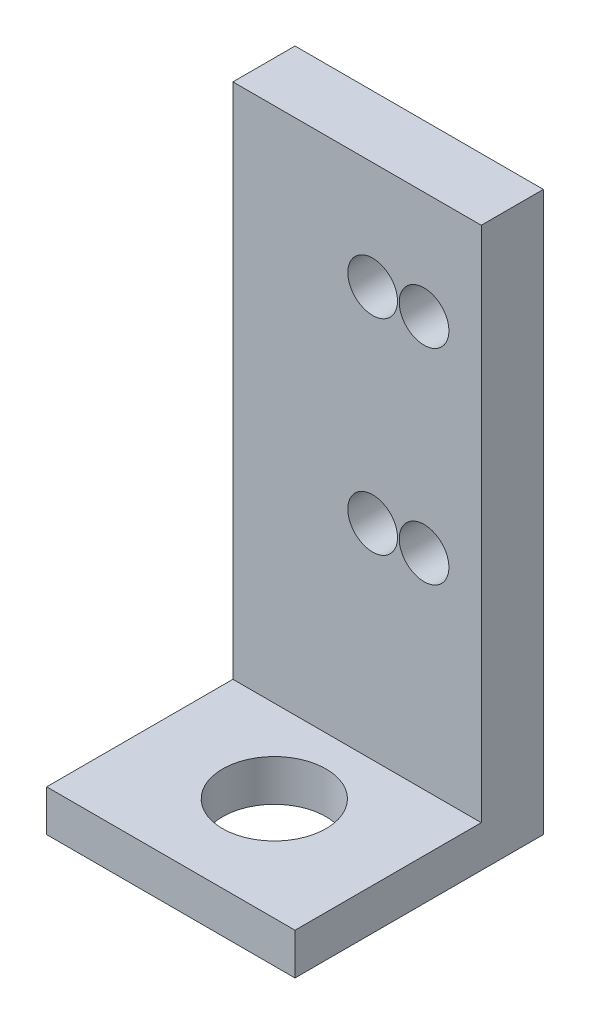
from build123d import *

# Parameters (mm, degrees)
SKETCH1_W           = 12
SKETCH1_H           = 27
BOSS_EXTRUDE1_DEPTH = 3
SKETCH2_W           = 12
SKETCH2_H           = 2
BOSS_EXTRUDE2_DEPTH = 9
SKETCH3_R           = 2.5
CUT_EXTRUDE1_DEPTH  = 10
SKETCH4_R           = 1.2
CUT_EXTRUDE2_DEPTH  = 10
SKETCH5_R           = 1.2
CUT_EXTRUDE3_DEPTH  = 10


with BuildPart() as part:
    # Sketch1 → Boss-Extrude1 (new body)
    with BuildSketch(Plane.XY):
        with Locations((6, 13.5)):
            Rectangle(SKETCH1_W, SKETCH1_H)
    extrude(amount=BOSS_EXTRUDE1_DEPTH)

    # Sketch2 → Boss-Extrude2 (add)
    with BuildSketch(Plane.XY.offset(3)):
        with Locations((6, 1)):
            Rectangle(SKETCH2_W, SKETCH2_H)
    extrude(amount=BOSS_EXTRUDE2_DEPTH)

    # Sketch3 → Cut-Extrude1 (cut)
    with BuildSketch(Plane(origin=(0, 2, 0), x_dir=(1, 0, 0), z_dir=(0, 1, 0))):
        with Locations((6, -7)):
            Circle(SKETCH3_R)
    extrude(amount=-CUT_EXTRUDE1_DEPTH, mode=Mode.SUBTRACT)

    # Sketch4 → Cut-Extrude2 (cut)
    with BuildSketch(Plane.XY.offset(3)):
        with Locations((9.236141261, 11.9)):
            Circle(SKETCH4_R)
        with Locations((9.236141261, 21.8)):
            Circle(SKETCH4_R)
    extrude(amount=-CUT_EXTRUDE2_DEPTH, mode=Mode.SUBTRACT)

    # Sketch5 → Cut-Extrude3 (cut)
    with BuildSketch(Plane.XY.offset(3)):
        with Locations((6.752182316, 11.9)):
            Circle(SKETCH5_R)
        with Locations((6.752182316, 21.8)):
            Circle(SKETCH5_R)
    extrude(amount=-CUT_EXTRUDE3_DEPTH, mode=Mode.SUBTRACT)


solid = part.part
